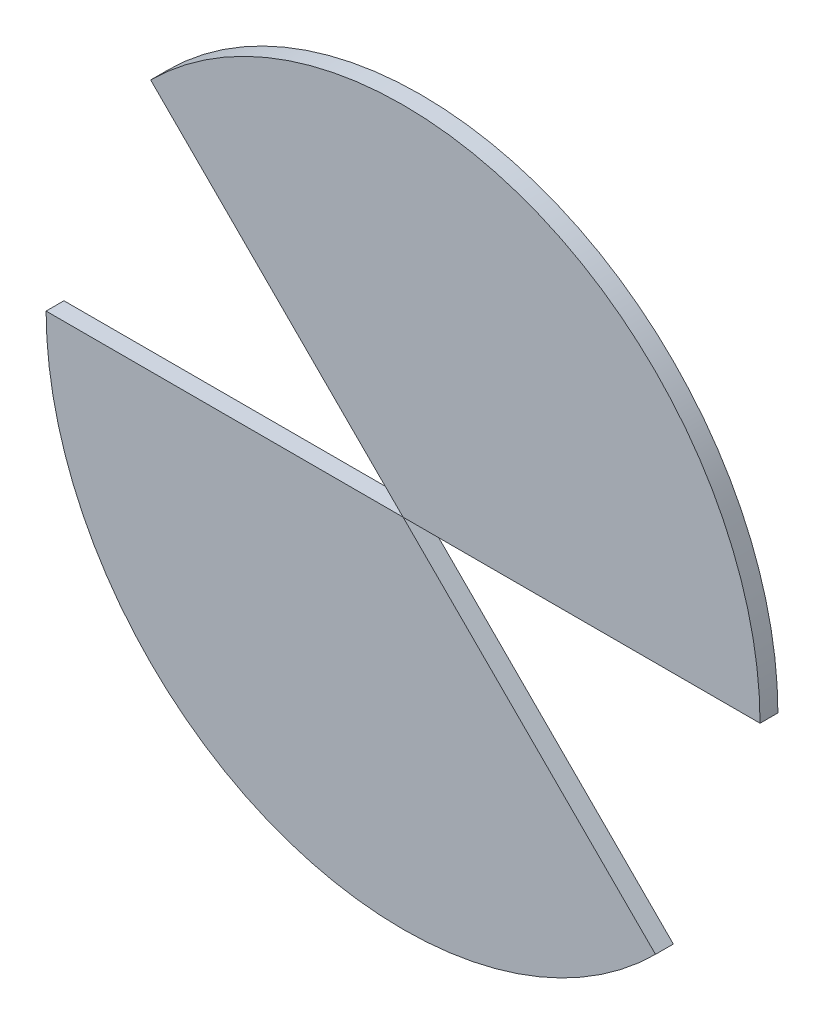
from build123d import *

# Parameters (mm, degrees)
BOSS_EXTRUDE1_DEPTH = 5
BOSS_EXTRUDE2_DEPTH = 5


with BuildPart() as part:
    # Sketch1 → Boss-Extrude1 (new body)
    with BuildSketch(Plane.XY):
        with BuildLine():
            Line((0, 0), (-100, 0))
            ThreePointArc((-100, 0), (-38.268343237, -92.387953251), (70.710678119, -70.710678119))
            Line((70.710678119, -70.710678119), (0, 0))
        make_face()
    extrude(amount=BOSS_EXTRUDE1_DEPTH)


with BuildPart() as body_2:
    # Sketch2 → Boss-Extrude2 (new body)
    with BuildSketch(Plane.XY):
        with BuildLine():
            Line((0, 0), (100, 0))
            ThreePointArc((100, 0), (38.268343237, 92.387953251), (-70.710678119, 70.710678119))
            Line((-70.710678119, 70.710678119), (0, 0))
        make_face()
    extrude(amount=BOSS_EXTRUDE2_DEPTH)


solid = Compound([part.part, body_2.part])
